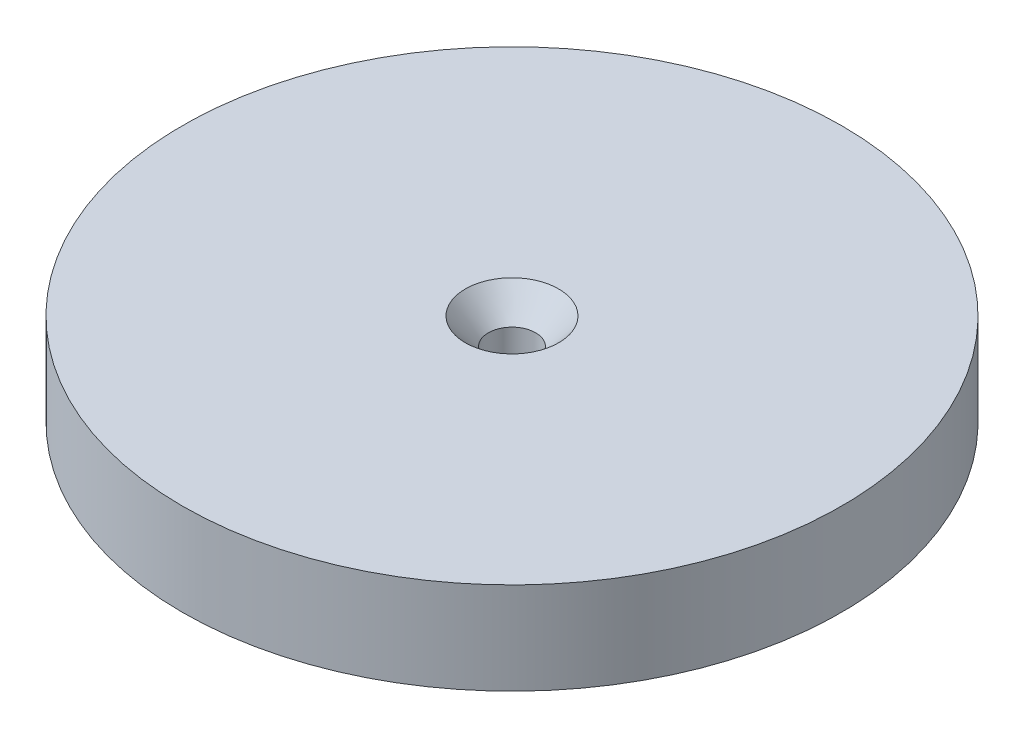
from build123d import *

# Parameters (mm, degrees)
SKETCH1_R                                        = 45.466
BOSS_EXTRUDE1_DEPTH                              = 25.4
SKETCH3_R                                        = 20.32
CUT_EXTRUDE1_DEPTH                               = 12.7
CSK_FOR_1_4_FLAT_HEAD_MACHINE_SCREW1_D           = 6.5278
CSK_FOR_1_4_FLAT_HEAD_MACHINE_SCREW1_DEPTH       = 25.4
CSK_FOR_1_4_FLAT_HEAD_MACHINE_SCREW1_CSINK_D     = 12.8778
CSK_FOR_1_4_FLAT_HEAD_MACHINE_SCREW1_CSINK_ANGLE = 82
CSK_FOR_1_4_FLAT_HEAD_MACHINE_SCREW1_TIP         = 1.961148974
SKETCH9_R                                        = 53.031918303
CUT_EXTRUDE3_DEPTH                               = 12.7


with BuildPart() as part:
    # Sketch1 → Boss-Extrude1 (new body)
    with BuildSketch(Plane(origin=(0, 0, 0), x_dir=(1, 0, 0), z_dir=(0, 1, 0))):
        Circle(SKETCH1_R)
    extrude(amount=BOSS_EXTRUDE1_DEPTH)

    # Sketch3 → Cut-Extrude1 (cut)
    with BuildSketch(Plane.XZ):
        Circle(SKETCH3_R)
    extrude(amount=-CUT_EXTRUDE1_DEPTH, mode=Mode.SUBTRACT)

    # CSK for 1/4 Flat Head Machine Screw1
    with Locations(Plane(origin=(0, 25.4, 0), x_dir=(1, 0, 0), z_dir=(0, 1, 0))):
        with Locations((0, 0)):
            CounterSinkHole(CSK_FOR_1_4_FLAT_HEAD_MACHINE_SCREW1_D / 2, CSK_FOR_1_4_FLAT_HEAD_MACHINE_SCREW1_CSINK_D / 2, depth=CSK_FOR_1_4_FLAT_HEAD_MACHINE_SCREW1_DEPTH, counter_sink_angle=CSK_FOR_1_4_FLAT_HEAD_MACHINE_SCREW1_CSINK_ANGLE)
            with Locations((0, 0, -(CSK_FOR_1_4_FLAT_HEAD_MACHINE_SCREW1_DEPTH + CSK_FOR_1_4_FLAT_HEAD_MACHINE_SCREW1_TIP / 2))):  # 118° drill point
                Cone(0, CSK_FOR_1_4_FLAT_HEAD_MACHINE_SCREW1_D / 2, CSK_FOR_1_4_FLAT_HEAD_MACHINE_SCREW1_TIP, mode=Mode.SUBTRACT)

    # Sketch9 → Cut-Extrude3 (cut)
    with BuildSketch(Plane.XZ):
        Circle(SKETCH9_R)
    extrude(amount=-CUT_EXTRUDE3_DEPTH, mode=Mode.SUBTRACT)


solid = part.part
